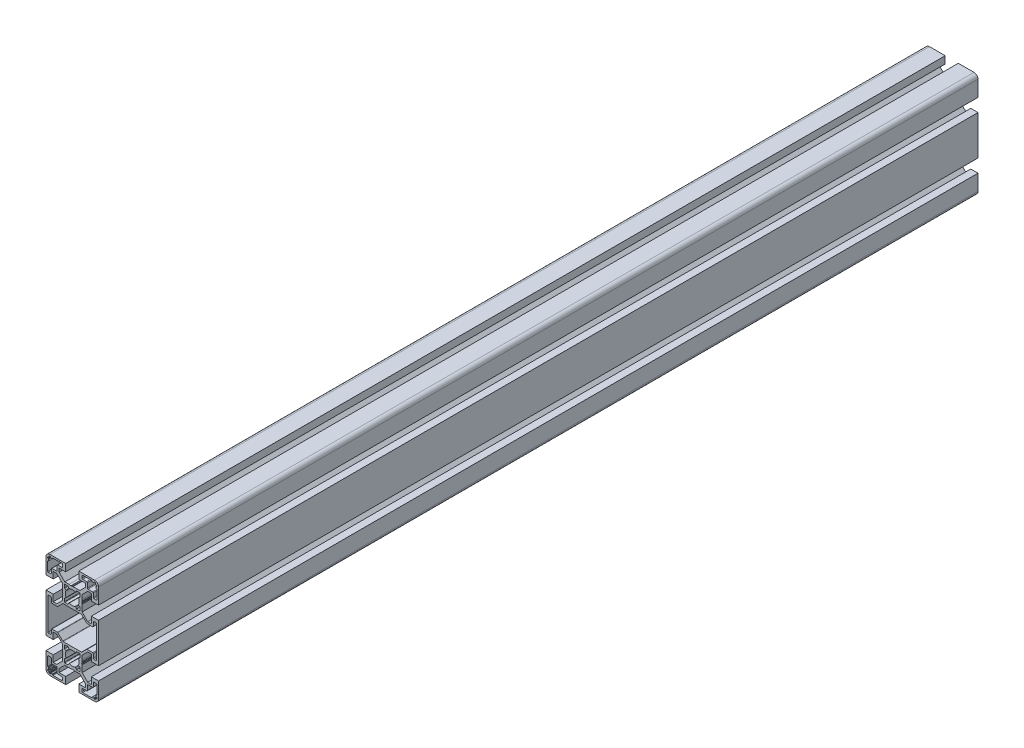
from build123d import *

# Parameters (mm, degrees)
BOSS_EXTRUDE1_DEPTH = 670


with BuildPart() as part:
    # Sketch1 → Boss-Extrude1 (new body)
    with BuildSketch(Plane.XY):
        with BuildLine():
            Line((-14.5, -30), (-14.5, -25))
            Line((-14.5, -25), (-20, -25))
            Line((-20, -25), (-20, -37))
            ThreePointArc((-20, -37), (-19.121320344, -39.121320344), (-17, -40))
            Line((-17, -40), (-5, -40))
            Line((-5, -40), (-5, -34.5))
            Line((-5, -34.5), (-10, -34.5))
            Line((-10, -34.5), (-10, -31.767766953))
            Line((-10, -31.767766953), (-5.732233047, -27.5))
            Line((-5.732233047, -27.5), (-0.653589838, -27.5))
            ThreePointArc((-0.653589838, -27.5), (-0.524180316, -27.482962913), (-0.403589838, -27.433012702))
            Line((-0.403589838, -27.433012702), (0, -27.2))
            Line((0, -27.2), (0.269615242, -27.355662433))
            ThreePointArc((0.269615242, -27.355662433), (0.519615242, -27.422649731), (0.769615242, -27.355662433))
            Line((0.769615242, -27.355662433), (1.018426372, -27.21201126))
            Line((1.018426372, -27.21201126), (2.5, -27.5))
            Line((2.5, -27.5), (5.732233047, -27.5))
            Line((5.732233047, -27.5), (10, -31.767766953))
            Line((10, -31.767766953), (10, -34.5))
            Line((10, -34.5), (5, -34.5))
            Line((5, -34.5), (5, -40))
            Line((5, -40), (17, -40))
            ThreePointArc((17, -40), (19.121320344, -39.121320344), (20, -37))
            Line((20, -37), (20, -25))
            Line((20, -25), (14.5, -25))
            Line((14.5, -25), (14.5, -30))
            Line((14.5, -30), (11.767766953, -30))
            Line((11.767766953, -30), (7.5, -25.732233047))
            Line((7.5, -25.732233047), (7.5, -20.653589838))
            ThreePointArc((7.5, -20.653589838), (7.482962913, -20.524180316), (7.433012702, -20.403589838))
            Line((7.433012702, -20.403589838), (7.2, -20))
            Line((7.2, -20), (7.355662433, -19.730384758))
            ThreePointArc((7.355662433, -19.730384758), (7.422649731, -19.480384758), (7.355662433, -19.230384758))
            Line((7.355662433, -19.230384758), (7.21201126, -18.981573628))
            Line((7.21201126, -18.981573628), (7.5, -17.5))
            Line((7.5, -17.5), (7.5, -14.267766953))
            Line((7.5, -14.267766953), (11.767766953, -10))
            Line((11.767766953, -10), (14.5, -10))
            Line((14.5, -10), (14.5, -15))
            Line((14.5, -15), (20, -15))
            Line((20, -15), (20, 15))
            Line((20, 15), (14.5, 15))
            Line((14.5, 15), (14.5, 10))
            Line((14.5, 10), (11.767766953, 10))
            Line((11.767766953, 10), (7.5, 14.267766953))
            Line((7.5, 14.267766953), (7.5, 19.346410162))
            ThreePointArc((7.5, 19.346410162), (7.482962913, 19.475819684), (7.433012702, 19.596410162))
            Line((7.433012702, 19.596410162), (7.2, 20))
            Line((7.2, 20), (7.355662433, 20.269615242))
            ThreePointArc((7.355662433, 20.269615242), (7.422649731, 20.519615242), (7.355662433, 20.769615242))
            Line((7.355662433, 20.769615242), (7.21201126, 21.018426372))
            Line((7.21201126, 21.018426372), (7.5, 22.5))
            Line((7.5, 22.5), (7.5, 25.732233047))
            Line((7.5, 25.732233047), (11.767766953, 30))
            Line((11.767766953, 30), (14.5, 30))
            Line((14.5, 30), (14.5, 25))
            Line((14.5, 25), (20, 25))
            Line((20, 25), (20, 37))
            ThreePointArc((20, 37), (19.121320344, 39.121320344), (17, 40))
            Line((17, 40), (5, 40))
            Line((5, 40), (5, 34.5))
            Line((5, 34.5), (10, 34.5))
            Line((10, 34.5), (10, 31.767766953))
            Line((10, 31.767766953), (5.732233047, 27.5))
            Line((5.732233047, 27.5), (0.653589838, 27.5))
            ThreePointArc((0.653589838, 27.5), (0.524180316, 27.482962913), (0.403589838, 27.433012702))
            Line((0.403589838, 27.433012702), (0, 27.2))
            Line((0, 27.2), (-0.269615242, 27.355662433))
            ThreePointArc((-0.269615242, 27.355662433), (-0.519615242, 27.422649731), (-0.769615242, 27.355662433))
            Line((-0.769615242, 27.355662433), (-1.018426372, 27.21201126))
            Line((-1.018426372, 27.21201126), (-2.5, 27.5))
            Line((-2.5, 27.5), (-5.732233047, 27.5))
            Line((-5.732233047, 27.5), (-10, 31.767766953))
            Line((-10, 31.767766953), (-10, 34.5))
            Line((-10, 34.5), (-5, 34.5))
            Line((-5, 34.5), (-5, 40))
            Line((-5, 40), (-17, 40))
            ThreePointArc((-17, 40), (-19.121320344, 39.121320344), (-20, 37))
            Line((-20, 37), (-20, 25))
            Line((-20, 25), (-14.5, 25))
            Line((-14.5, 25), (-14.5, 30))
            Line((-14.5, 30), (-11.767766953, 30))
            Line((-11.767766953, 30), (-7.5, 25.732233047))
            Line((-7.5, 25.732233047), (-7.5, 20.653589838))
            ThreePointArc((-7.5, 20.653589838), (-7.482962913, 20.524180316), (-7.433012702, 20.403589838))
            Line((-7.433012702, 20.403589838), (-7.2, 20))
            Line((-7.2, 20), (-7.355662433, 19.730384758))
            ThreePointArc((-7.355662433, 19.730384758), (-7.422649731, 19.480384758), (-7.355662433, 19.230384758))
            Line((-7.355662433, 19.230384758), (-7.21201126, 18.981573628))
            Line((-7.21201126, 18.981573628), (-7.5, 17.5))
            Line((-7.5, 17.5), (-7.5, 14.267766953))
            Line((-7.5, 14.267766953), (-11.767766953, 10))
            Line((-11.767766953, 10), (-14.5, 10))
            Line((-14.5, 10), (-14.5, 15))
            Line((-14.5, 15), (-20, 15))
            Line((-20, 15), (-20, -15))
            Line((-20, -15), (-14.5, -15))
            Line((-14.5, -15), (-14.5, -10))
            Line((-14.5, -10), (-11.767766953, -10))
            Line((-11.767766953, -10), (-7.5, -14.267766953))
            Line((-7.5, -14.267766953), (-7.5, -19.346410162))
            ThreePointArc((-7.5, -19.346410162), (-7.482962913, -19.475819684), (-7.433012702, -19.596410162))
            Line((-7.433012702, -19.596410162), (-7.2, -20))
            Line((-7.2, -20), (-7.355662433, -20.269615242))
            ThreePointArc((-7.355662433, -20.269615242), (-7.422649731, -20.519615242), (-7.355662433, -20.769615242))
            Line((-7.355662433, -20.769615242), (-7.21201126, -21.018426372))
            Line((-7.21201126, -21.018426372), (-7.5, -22.5))
            Line((-7.5, -22.5), (-7.5, -25.732233047))
            Line((-7.5, -25.732233047), (-11.767766953, -30))
            Line((-11.767766953, -30), (-14.5, -30))
        make_face()
        with BuildLine():
            Line((7.5, -38.2), (7.5, -36.5))
            ThreePointArc((7.5, -36.5), (7.646446609, -36.146446609), (8, -36))
            Line((8, -36), (11, -36))
            ThreePointArc((11, -36), (11.353553391, -35.853553391), (11.5, -35.5))
            Line((11.5, -35.5), (11.5, -32))
            ThreePointArc((11.5, -32), (11.646446609, -31.646446609), (12, -31.5))
            Line((12, -31.5), (15.5, -31.5))
            ThreePointArc((15.5, -31.5), (15.853553391, -31.353553391), (16, -31))
            Line((16, -31), (16, -28))
            ThreePointArc((16, -28), (16.146446609, -27.646446609), (16.5, -27.5))
            Line((16.5, -27.5), (18.2, -27.5))
            ThreePointArc((18.2, -27.5), (18.553553391, -27.646446609), (18.7, -28))
            Line((18.7, -28), (18.7, -34.7))
            ThreePointArc((18.7, -34.7), (18.612132034, -34.912132034), (18.4, -35))
            Line((18.4, -35), (18.3, -35))
            ThreePointArc((18.3, -35), (18.087867966, -35.087867966), (18, -35.3))
            Line((18, -35.3), (18, -36.3))
            ThreePointArc((18, -36.3), (18.087867966, -36.512132034), (18.3, -36.6))
            Line((18.3, -36.6), (18.4, -36.6))
            ThreePointArc((18.4, -36.6), (18.612132034, -36.687867966), (18.7, -36.9))
            Line((18.7, -36.9), (18.7, -37.3))
            ThreePointArc((18.7, -37.3), (18.612132034, -37.512132034), (18.4, -37.6))
            Line((18.4, -37.6), (17.9, -37.6))
            ThreePointArc((17.9, -37.6), (17.687867966, -37.687867966), (17.6, -37.9))
            Line((17.6, -37.9), (17.6, -38.4))
            ThreePointArc((17.6, -38.4), (17.512132034, -38.612132034), (17.3, -38.7))
            Line((17.3, -38.7), (16.9, -38.7))
            ThreePointArc((16.9, -38.7), (16.687867966, -38.612132034), (16.6, -38.4))
            Line((16.6, -38.4), (16.6, -38.3))
            ThreePointArc((16.6, -38.3), (16.512132034, -38.087867966), (16.3, -38))
            Line((16.3, -38), (15.3, -38))
            ThreePointArc((15.3, -38), (15.087867966, -38.087867966), (15, -38.3))
            Line((15, -38.3), (15, -38.4))
            ThreePointArc((15, -38.4), (14.912132034, -38.612132034), (14.7, -38.7))
            Line((14.7, -38.7), (8, -38.7))
            ThreePointArc((8, -38.7), (7.646446609, -38.553553391), (7.5, -38.2))
        make_face(mode=Mode.SUBTRACT)
        with BuildLine():
            Line((7.5, 36.5), (7.5, 38.2))
            ThreePointArc((7.5, 38.2), (7.646446609, 38.553553391), (8, 38.7))
            Line((8, 38.7), (14.7, 38.7))
            ThreePointArc((14.7, 38.7), (14.912132034, 38.612132034), (15, 38.4))
            Line((15, 38.4), (15, 38.3))
            ThreePointArc((15, 38.3), (15.087867966, 38.087867966), (15.3, 38))
            Line((15.3, 38), (16.3, 38))
            ThreePointArc((16.3, 38), (16.512132034, 38.087867966), (16.6, 38.3))
            Line((16.6, 38.3), (16.6, 38.4))
            ThreePointArc((16.6, 38.4), (16.687867966, 38.612132034), (16.9, 38.7))
            Line((16.9, 38.7), (17.3, 38.7))
            ThreePointArc((17.3, 38.7), (17.512132034, 38.612132034), (17.6, 38.4))
            Line((17.6, 38.4), (17.6, 37.9))
            ThreePointArc((17.6, 37.9), (17.687867966, 37.687867966), (17.9, 37.6))
            Line((17.9, 37.6), (18.4, 37.6))
            ThreePointArc((18.4, 37.6), (18.612132034, 37.512132034), (18.7, 37.3))
            Line((18.7, 37.3), (18.7, 36.9))
            ThreePointArc((18.7, 36.9), (18.612132034, 36.687867966), (18.4, 36.6))
            Line((18.4, 36.6), (18.3, 36.6))
            ThreePointArc((18.3, 36.6), (18.087867966, 36.512132034), (18, 36.3))
            Line((18, 36.3), (18, 35.3))
            ThreePointArc((18, 35.3), (18.087867966, 35.087867966), (18.3, 35))
            Line((18.3, 35), (18.4, 35))
            ThreePointArc((18.4, 35), (18.612132034, 34.912132034), (18.7, 34.7))
            Line((18.7, 34.7), (18.7, 28))
            ThreePointArc((18.7, 28), (18.553553391, 27.646446609), (18.2, 27.5))
            Line((18.2, 27.5), (16.5, 27.5))
            ThreePointArc((16.5, 27.5), (16.146446609, 27.646446609), (16, 28))
            Line((16, 28), (16, 31))
            ThreePointArc((16, 31), (15.853553391, 31.353553391), (15.5, 31.5))
            Line((15.5, 31.5), (12, 31.5))
            ThreePointArc((12, 31.5), (11.646446609, 31.646446609), (11.5, 32))
            Line((11.5, 32), (11.5, 35.5))
            ThreePointArc((11.5, 35.5), (11.353553391, 35.853553391), (11, 36))
            Line((11, 36), (8, 36))
            ThreePointArc((8, 36), (7.646446609, 36.146446609), (7.5, 36.5))
        make_face(mode=Mode.SUBTRACT)
        with BuildLine():
            Line((-18.5, -12), (-18.5, 12))
            ThreePointArc((-18.5, 12), (-18.353553391, 12.353553391), (-18, 12.5))
            Line((-18, 12.5), (-16.5, 12.5))
            ThreePointArc((-16.5, 12.5), (-16.146446609, 12.353553391), (-16, 12))
            Line((-16, 12), (-16, 9))
            ThreePointArc((-16, 9), (-15.853553391, 8.646446609), (-15.5, 8.5))
            Line((-15.5, 8.5), (-11.353553391, 8.5))
            ThreePointArc((-11.353553391, 8.5), (-11.162211674, 8.538060234), (-11, 8.646446609))
            Line((-11, 8.646446609), (-7.292893219, 12.353553391))
            ThreePointArc((-7.292893219, 12.353553391), (-7.130681544, 12.461939766), (-6.939339828, 12.5))
            Line((-6.939339828, 12.5), (6.939339828, 12.5))
            ThreePointArc((6.939339828, 12.5), (7.130681544, 12.461939766), (7.292893219, 12.353553391))
            Line((7.292893219, 12.353553391), (11, 8.646446609))
            ThreePointArc((11, 8.646446609), (11.162211674, 8.538060234), (11.353553391, 8.5))
            Line((11.353553391, 8.5), (15.5, 8.5))
            ThreePointArc((15.5, 8.5), (15.853553391, 8.646446609), (16, 9))
            Line((16, 9), (16, 12))
            ThreePointArc((16, 12), (16.146446609, 12.353553391), (16.5, 12.5))
            Line((16.5, 12.5), (18, 12.5))
            ThreePointArc((18, 12.5), (18.353553391, 12.353553391), (18.5, 12))
            Line((18.5, 12), (18.5, -12))
            ThreePointArc((18.5, -12), (18.353553391, -12.353553391), (18, -12.5))
            Line((18, -12.5), (16.5, -12.5))
            ThreePointArc((16.5, -12.5), (16.146446609, -12.353553391), (16, -12))
            Line((16, -12), (16, -9))
            ThreePointArc((16, -9), (15.853553391, -8.646446609), (15.5, -8.5))
            Line((15.5, -8.5), (11.353553391, -8.5))
            ThreePointArc((11.353553391, -8.5), (11.162211674, -8.538060234), (11, -8.646446609))
            Line((11, -8.646446609), (7.292893219, -12.353553391))
            ThreePointArc((7.292893219, -12.353553391), (7.130681544, -12.461939766), (6.939339828, -12.5))
            Line((6.939339828, -12.5), (-6.939339828, -12.5))
            ThreePointArc((-6.939339828, -12.5), (-7.130681544, -12.461939766), (-7.292893219, -12.353553391))
            Line((-7.292893219, -12.353553391), (-11, -8.646446609))
            ThreePointArc((-11, -8.646446609), (-11.162211674, -8.538060234), (-11.353553391, -8.5))
            Line((-11.353553391, -8.5), (-15.5, -8.5))
            ThreePointArc((-15.5, -8.5), (-15.853553391, -8.646446609), (-16, -9))
            Line((-16, -9), (-16, -12))
            ThreePointArc((-16, -12), (-16.146446609, -12.353553391), (-16.5, -12.5))
            Line((-16.5, -12.5), (-18, -12.5))
            ThreePointArc((-18, -12.5), (-18.353553391, -12.353553391), (-18.5, -12))
        make_face(mode=Mode.SUBTRACT)
        with BuildLine():
            Line((-18.7, 36.9), (-18.7, 37.3))
            ThreePointArc((-18.7, 37.3), (-18.612132034, 37.512132034), (-18.4, 37.6))
            Line((-18.4, 37.6), (-17.9, 37.6))
            ThreePointArc((-17.9, 37.6), (-17.687867966, 37.687867966), (-17.6, 37.9))
            Line((-17.6, 37.9), (-17.6, 38.4))
            ThreePointArc((-17.6, 38.4), (-17.512132034, 38.612132034), (-17.3, 38.7))
            Line((-17.3, 38.7), (-16.9, 38.7))
            ThreePointArc((-16.9, 38.7), (-16.687867966, 38.612132034), (-16.6, 38.4))
            Line((-16.6, 38.4), (-16.6, 38.3))
            ThreePointArc((-16.6, 38.3), (-16.512132034, 38.087867966), (-16.3, 38))
            Line((-16.3, 38), (-15.3, 38))
            ThreePointArc((-15.3, 38), (-15.087867966, 38.087867966), (-15, 38.3))
            Line((-15, 38.3), (-15, 38.4))
            ThreePointArc((-15, 38.4), (-14.912132034, 38.612132034), (-14.7, 38.7))
            Line((-14.7, 38.7), (-8, 38.7))
            ThreePointArc((-8, 38.7), (-7.646446609, 38.553553391), (-7.5, 38.2))
            Line((-7.5, 38.2), (-7.5, 36.5))
            ThreePointArc((-7.5, 36.5), (-7.646446609, 36.146446609), (-8, 36))
            Line((-8, 36), (-11, 36))
            ThreePointArc((-11, 36), (-11.353553391, 35.853553391), (-11.5, 35.5))
            Line((-11.5, 35.5), (-11.5, 32))
            ThreePointArc((-11.5, 32), (-11.646446609, 31.646446609), (-12, 31.5))
            Line((-12, 31.5), (-15.5, 31.5))
            ThreePointArc((-15.5, 31.5), (-15.853553391, 31.353553391), (-16, 31))
            Line((-16, 31), (-16, 28))
            ThreePointArc((-16, 28), (-16.146446609, 27.646446609), (-16.5, 27.5))
            Line((-16.5, 27.5), (-18.2, 27.5))
            ThreePointArc((-18.2, 27.5), (-18.553553391, 27.646446609), (-18.7, 28))
            Line((-18.7, 28), (-18.7, 34.7))
            ThreePointArc((-18.7, 34.7), (-18.612132034, 34.912132034), (-18.4, 35))
            Line((-18.4, 35), (-18.3, 35))
            ThreePointArc((-18.3, 35), (-18.087867966, 35.087867966), (-18, 35.3))
            Line((-18, 35.3), (-18, 36.3))
            ThreePointArc((-18, 36.3), (-18.087867966, 36.512132034), (-18.3, 36.6))
            Line((-18.3, 36.6), (-18.4, 36.6))
            ThreePointArc((-18.4, 36.6), (-18.612132034, 36.687867966), (-18.7, 36.9))
        make_face(mode=Mode.SUBTRACT)
        with BuildLine():
            Line((-17.9, -37.6), (-18.4, -37.6))
            ThreePointArc((-18.4, -37.6), (-18.612132034, -37.512132034), (-18.7, -37.3))
            Line((-18.7, -37.3), (-18.7, -36.9))
            ThreePointArc((-18.7, -36.9), (-18.612132034, -36.687867966), (-18.4, -36.6))
            Line((-18.4, -36.6), (-18.3, -36.6))
            ThreePointArc((-18.3, -36.6), (-18.087867966, -36.512132034), (-18, -36.3))
            Line((-18, -36.3), (-18, -35.3))
            ThreePointArc((-18, -35.3), (-18.087867966, -35.087867966), (-18.3, -35))
            Line((-18.3, -35), (-18.4, -35))
            ThreePointArc((-18.4, -35), (-18.612132034, -34.912132034), (-18.7, -34.7))
            Line((-18.7, -34.7), (-18.7, -28))
            ThreePointArc((-18.7, -28), (-18.553553391, -27.646446609), (-18.2, -27.5))
            Line((-18.2, -27.5), (-16.5, -27.5))
            ThreePointArc((-16.5, -27.5), (-16.146446609, -27.646446609), (-16, -28))
            Line((-16, -28), (-16, -31))
            ThreePointArc((-16, -31), (-15.853553391, -31.353553391), (-15.5, -31.5))
            Line((-15.5, -31.5), (-12, -31.5))
            ThreePointArc((-12, -31.5), (-11.646446609, -31.646446609), (-11.5, -32))
            Line((-11.5, -32), (-11.5, -35.5))
            ThreePointArc((-11.5, -35.5), (-11.353553391, -35.853553391), (-11, -36))
            Line((-11, -36), (-8, -36))
            ThreePointArc((-8, -36), (-7.646446609, -36.146446609), (-7.5, -36.5))
            Line((-7.5, -36.5), (-7.5, -38.2))
            ThreePointArc((-7.5, -38.2), (-7.646446609, -38.553553391), (-8, -38.7))
            Line((-8, -38.7), (-14.7, -38.7))
            ThreePointArc((-14.7, -38.7), (-14.912132034, -38.612132034), (-15, -38.4))
            Line((-15, -38.4), (-15, -38.3))
            ThreePointArc((-15, -38.3), (-15.087867966, -38.087867966), (-15.3, -38))
            Line((-15.3, -38), (-16.3, -38))
            ThreePointArc((-16.3, -38), (-16.512132034, -38.087867966), (-16.6, -38.3))
            Line((-16.6, -38.3), (-16.6, -38.4))
            ThreePointArc((-16.6, -38.4), (-16.687867966, -38.612132034), (-16.9, -38.7))
            Line((-16.9, -38.7), (-17.3, -38.7))
            ThreePointArc((-17.3, -38.7), (-17.512132034, -38.612132034), (-17.6, -38.4))
            Line((-17.6, -38.4), (-17.6, -37.9))
            ThreePointArc((-17.6, -37.9), (-17.687867966, -37.687867966), (-17.9, -37.6))
        make_face(mode=Mode.SUBTRACT)
        with BuildLine():
            Line((-6, 14.3), (-6, 16.620000047))
            ThreePointArc((-6, 16.620000047), (-5.957247895, 16.774348744), (-5.841176531, 16.884705897))
            Line((-5.841176531, 16.884705897), (-4.889899438, 17.392053958))
            ThreePointArc((-4.889899438, 17.392053958), (-4.746540334, 17.561683668), (-4.759125952, 17.783421516))
            ThreePointArc((-4.759125952, 17.783421516), (-5.250000646, 20.000000636), (-4.75912657, 22.216579892))
            ThreePointArc((-4.75912657, 22.216579892), (-4.746541014, 22.438317744), (-4.889900165, 22.607947414))
            Line((-4.889900165, 22.607947414), (-5.841176457, 23.115294707))
            ThreePointArc((-5.841176457, 23.115294707), (-5.957247874, 23.225651864), (-6, 23.380000597))
            Line((-6, 23.380000597), (-6, 25.7))
            ThreePointArc((-6, 25.7), (-5.912132034, 25.912132034), (-5.7, 26))
            Line((-5.7, 26), (-3.379999618, 26))
            ThreePointArc((-3.379999618, 26), (-3.225650885, 25.957247874), (-3.115293728, 25.841176457))
            Line((-3.115293728, 25.841176457), (-2.607946775, 24.889900804))
            ThreePointArc((-2.607946775, 24.889900804), (-2.438317106, 24.746541653), (-2.216579254, 24.759127209))
            ThreePointArc((-2.216579254, 24.759127209), (-7.3e-07, 25.250001284), (2.216577795, 24.759127209))
            ThreePointArc((2.216577795, 24.759127209), (2.438315646, 24.746541653), (2.607945316, 24.889900804))
            Line((2.607945316, 24.889900804), (3.115292269, 25.841176457))
            ThreePointArc((3.115292269, 25.841176457), (3.225649425, 25.957247874), (3.379998158, 26))
            Line((3.379998158, 26), (5.7, 26))
            ThreePointArc((5.7, 26), (5.912132034, 25.912132034), (6, 25.7))
            Line((6, 25.7), (6, 23.380003468))
            ThreePointArc((6, 23.380003468), (5.957247895, 23.225654771), (5.841176531, 23.115297618))
            Line((5.841176531, 23.115297618), (4.889897979, 22.607948778))
            ThreePointArc((4.889897979, 22.607948778), (4.746538875, 22.438319068), (4.759124493, 22.21658122))
            ThreePointArc((4.759124493, 22.21658122), (5.249999187, 20.0000021), (4.759125111, 17.783422844))
            ThreePointArc((4.759125111, 17.783422844), (4.746539555, 17.561684992), (4.889898706, 17.392055322))
            Line((4.889898706, 17.392055322), (5.841176457, 16.884707251))
            ThreePointArc((5.841176457, 16.884707251), (5.957247874, 16.774350094), (6, 16.620001361))
            Line((6, 16.620001361), (6, 14.3))
            ThreePointArc((6, 14.3), (5.912132034, 14.087867966), (5.7, 14))
            Line((5.7, 14), (3.379999618, 14))
            ThreePointArc((3.379999618, 14), (3.225650885, 14.042752126), (3.115293728, 14.158823543))
            Line((3.115293728, 14.158823543), (2.607945316, 15.110101932))
            ThreePointArc((2.607945316, 15.110101932), (2.438315646, 15.253461084), (2.216577795, 15.240875528))
            ThreePointArc((2.216577795, 15.240875528), (-7.3e-07, 14.750001452), (-2.216579254, 15.240875528))
            ThreePointArc((-2.216579254, 15.240875528), (-2.438317106, 15.253461084), (-2.607946775, 15.110101932))
            Line((-2.607946775, 15.110101932), (-3.115295188, 14.158823543))
            ThreePointArc((-3.115295188, 14.158823543), (-3.225652344, 14.042752126), (-3.380001077, 14))
            Line((-3.380001077, 14), (-5.7, 14))
            ThreePointArc((-5.7, 14), (-5.912132034, 14.087867966), (-6, 14.3))
        make_face(mode=Mode.SUBTRACT)
        with BuildLine():
            Line((-6, -25.7), (-6, -23.379999953))
            ThreePointArc((-6, -23.379999953), (-5.957247895, -23.225651256), (-5.841176531, -23.115294103))
            Line((-5.841176531, -23.115294103), (-4.889899438, -22.607946042))
            ThreePointArc((-4.889899438, -22.607946042), (-4.746540334, -22.438316332), (-4.759125952, -22.216578484))
            ThreePointArc((-4.759125952, -22.216578484), (-5.250000646, -19.999999364), (-4.75912657, -17.783420108))
            ThreePointArc((-4.75912657, -17.783420108), (-4.746541014, -17.561682256), (-4.889900165, -17.392052586))
            Line((-4.889900165, -17.392052586), (-5.841176457, -16.884705293))
            ThreePointArc((-5.841176457, -16.884705293), (-5.957247874, -16.774348136), (-6, -16.619999403))
            Line((-6, -16.619999403), (-6, -14.3))
            ThreePointArc((-6, -14.3), (-5.912132034, -14.087867966), (-5.7, -14))
            Line((-5.7, -14), (-3.379999618, -14))
            ThreePointArc((-3.379999618, -14), (-3.225650885, -14.042752126), (-3.115293728, -14.158823543))
            Line((-3.115293728, -14.158823543), (-2.607946775, -15.110099196))
            ThreePointArc((-2.607946775, -15.110099196), (-2.438317106, -15.253458347), (-2.216579254, -15.240872791))
            ThreePointArc((-2.216579254, -15.240872791), (-7.3e-07, -14.749998716), (2.216577795, -15.240872791))
            ThreePointArc((2.216577795, -15.240872791), (2.438315646, -15.253458347), (2.607945316, -15.110099196))
            Line((2.607945316, -15.110099196), (3.115292269, -14.158823543))
            ThreePointArc((3.115292269, -14.158823543), (3.225649425, -14.042752126), (3.379998158, -14))
            Line((3.379998158, -14), (5.7, -14))
            ThreePointArc((5.7, -14), (5.912132034, -14.087867966), (6, -14.3))
            Line((6, -14.3), (6, -16.619996532))
            ThreePointArc((6, -16.619996532), (5.957247895, -16.774345229), (5.841176531, -16.884702382))
            Line((5.841176531, -16.884702382), (4.889897979, -17.392051222))
            ThreePointArc((4.889897979, -17.392051222), (4.746538875, -17.561680932), (4.759124493, -17.78341878))
            ThreePointArc((4.759124493, -17.78341878), (5.249999187, -19.9999979), (4.759125111, -22.216577156))
            ThreePointArc((4.759125111, -22.216577156), (4.746539555, -22.438315008), (4.889898706, -22.607944678))
            Line((4.889898706, -22.607944678), (5.841176457, -23.115292749))
            ThreePointArc((5.841176457, -23.115292749), (5.957247874, -23.225649906), (6, -23.379998639))
            Line((6, -23.379998639), (6, -25.7))
            ThreePointArc((6, -25.7), (5.912132034, -25.912132034), (5.7, -26))
            Line((5.7, -26), (3.379999618, -26))
            ThreePointArc((3.379999618, -26), (3.225650885, -25.957247874), (3.115293728, -25.841176457))
            Line((3.115293728, -25.841176457), (2.607945316, -24.889898068))
            ThreePointArc((2.607945316, -24.889898068), (2.438315646, -24.746538916), (2.216577795, -24.759124472))
            ThreePointArc((2.216577795, -24.759124472), (-7.3e-07, -25.249998548), (-2.216579254, -24.759124472))
            ThreePointArc((-2.216579254, -24.759124472), (-2.438317106, -24.746538916), (-2.607946775, -24.889898068))
            Line((-2.607946775, -24.889898068), (-3.115295188, -25.841176457))
            ThreePointArc((-3.115295188, -25.841176457), (-3.225652344, -25.957247874), (-3.380001077, -26))
            Line((-3.380001077, -26), (-5.7, -26))
            ThreePointArc((-5.7, -26), (-5.912132034, -25.912132034), (-6, -25.7))
        make_face(mode=Mode.SUBTRACT)
    extrude(amount=-BOSS_EXTRUDE1_DEPTH)


solid = part.part
